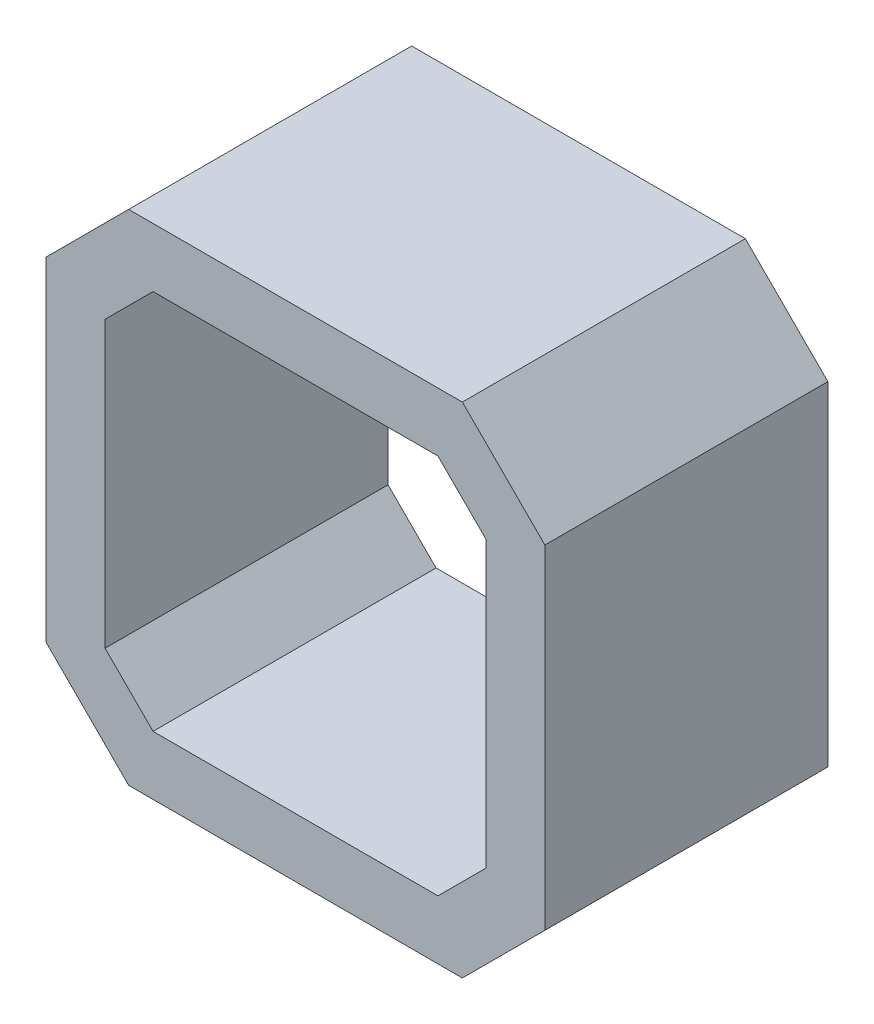
from build123d import *

# Parameters (mm, degrees)
BOSS_EXTRUDE1_DEPTH = 24


with BuildPart() as part:
    # Sketch1 → Boss-Extrude1 (new body)
    with BuildSketch(Plane.XY):
        Polygon((-21.15, 14.15), (-14.15, 21.15), (14.15, 21.15), (21.15, 14.15), (21.15, -14.15), (14.15, -21.15), (-14.15, -21.15), (-21.15, -14.15), align=None)
        Polygon((-12.078932188, 16.15), (12.078932188, 16.15), (16.15, 12.078932188), (16.15, -12.078932188), (12.078932188, -16.15), (-12.078932188, -16.15), (-16.15, -12.078932188), (-16.15, 12.078932188), align=None, mode=Mode.SUBTRACT)
    extrude(amount=BOSS_EXTRUDE1_DEPTH)


solid = part.part
